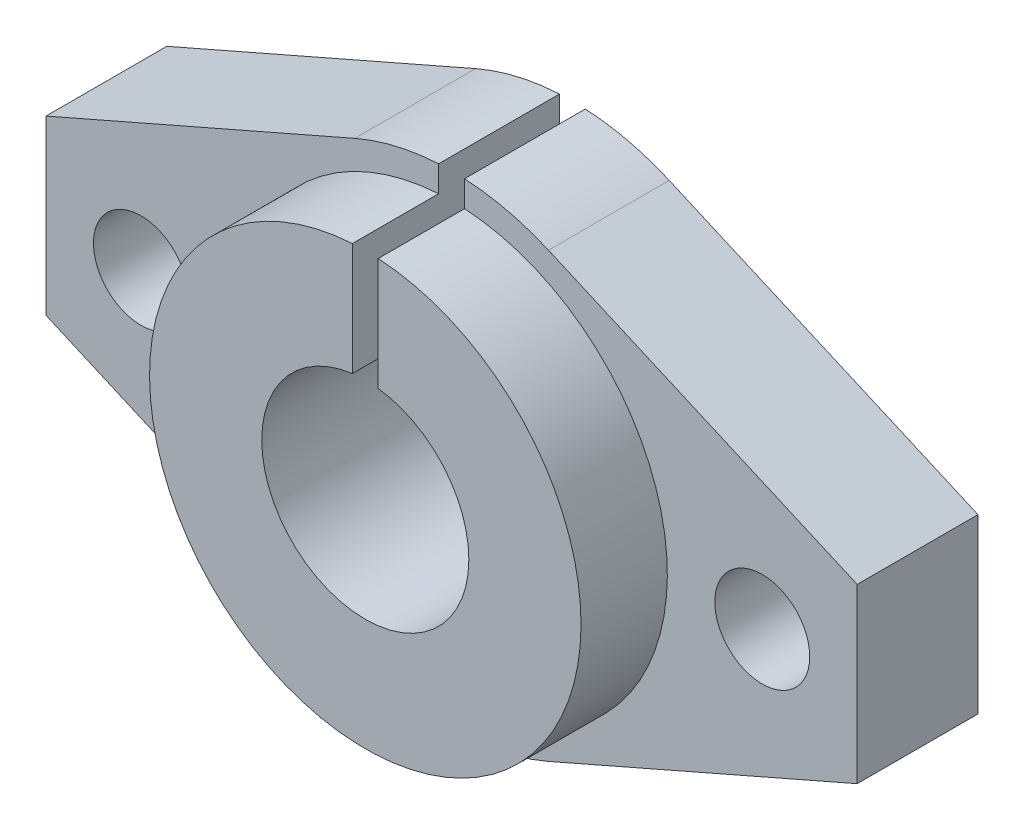
from build123d import *

# Parameters (mm, degrees)
BOSS_EXTRUDE1_DEPTH = 7
SKETCH2_R           = 12.5
BOSS_EXTRUDE2_DEPTH = 5
SKETCH3_R           = 6
CUT_EXTRUDE1_DEPTH  = 13
SKETCH4_R           = 2.75
CUT_EXTRUDE2_DEPTH  = 8
SKETCH5_W           = 1.5
SKETCH5_H           = 20
CUT_EXTRUDE3_DEPTH  = 13


with BuildPart() as part:
    # Sketch1 → Boss-Extrude1 (new body)
    with BuildSketch(Plane.XY):
        with BuildLine():
            Line((-5.611444446, 12.826211102), (-23.5, 5))
            Line((-23.5, 5), (-23.5, -5))
            Line((-23.5, -5), (-5.611444446, -12.826211102))
            ThreePointArc((-5.611444446, -12.826211102), (0, -14), (5.611444446, -12.826211102))
            Line((5.611444446, -12.826211102), (23.5, -5))
            Line((23.5, -5), (23.5, 5))
            Line((23.5, 5), (5.611444446, 12.826211102))
            ThreePointArc((5.611444446, 12.826211102), (0, 14), (-5.611444446, 12.826211102))
        make_face()
    extrude(amount=BOSS_EXTRUDE1_DEPTH)

    # Sketch2 → Boss-Extrude2 (add)
    with BuildSketch(Plane.XY.offset(7)):
        Circle(SKETCH2_R)
    extrude(amount=BOSS_EXTRUDE2_DEPTH)

    # Sketch3 → Cut-Extrude1 (cut, through all)
    with BuildSketch(Plane.XY.offset(12)):
        Circle(SKETCH3_R)
    extrude(amount=-CUT_EXTRUDE1_DEPTH, mode=Mode.SUBTRACT)

    # Sketch4 → Cut-Extrude2 (cut, through all)
    with BuildSketch(Plane.XY.offset(7)):
        with Locations((-18, 0)):
            Circle(SKETCH4_R)
        with Locations((18, 0)):
            Circle(SKETCH4_R)
    extrude(amount=-CUT_EXTRUDE2_DEPTH, mode=Mode.SUBTRACT)

    # Sketch5 → Cut-Extrude3 (cut, through all)
    with BuildSketch(Plane.XY.offset(12)):
        with Locations((0, 15)):
            Rectangle(SKETCH5_W, SKETCH5_H)
    extrude(amount=-CUT_EXTRUDE3_DEPTH, mode=Mode.SUBTRACT)


solid = part.part
